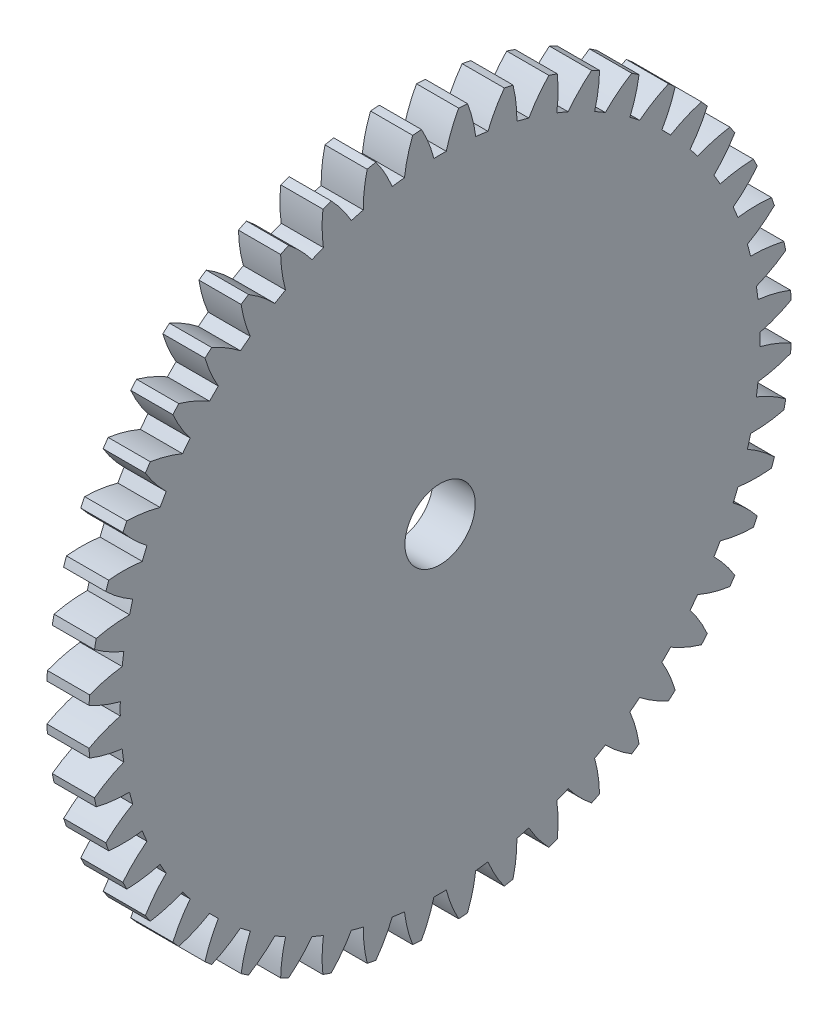
from build123d import *

# Parameters (mm, degrees)
BASPROSKE_W     = 3
BASPROSKE_H     = 25
TOOTHCUT_DEPTH  = 36.482389998
TEETHCUTS_COUNT = 48
TEETHCUTS_ANGLE = 352.5
BORSKE_R        = 2.5
BORE_DEPTH      = 50.0000508


with BuildPart() as part:
    # BasProSke → Base-Revolve (revolve)
    with BuildSketch(Plane(origin=(0, 0, 0), x_dir=(1, 0, 0), z_dir=(0, 1, 0)), mode=Mode.PRIVATE) as base_revolve_sk:
        with Locations((1.5, 12.5)):
            Rectangle(BASPROSKE_W, BASPROSKE_H)
    revolve(base_revolve_sk.sketch.rotate(Axis((-10, 0, 0), (1, 0, 0)), 180), axis=Axis((-10, 0, 0), (1, 0, 0)))

    # TooCutSke → ToothCut (cut, through all)
    with BuildSketch(Plane(origin=(0, 0, 0), x_dir=(0, 0, -1), z_dir=(1, 0, 0))):
        with BuildLine():
            ThreePointArc((0.439519311, 22.744753764), (0, 22.749), (-0.439519311, 22.744753764))
            ThreePointArc((-0.439519311, 22.744753764), (-0.815652087, 23.895542925), (-1.33363602, 24.989839138))
            ThreePointArc((-1.33363602, 24.989839138), (0, 25.0254), (1.33363602, 24.989839138))
            ThreePointArc((1.33363602, 24.989839138), (0.815652087, 23.895542925), (0.439519311, 22.744753764))
        make_face()
    toothcut = extrude(amount=TOOTHCUT_DEPTH, mode=Mode.SUBTRACT)

    # TeethCuts: ToothCut ×48 about axis
    teethcuts_axis = Axis((-10, 0, 0), (1, 0, 0))
    for i in range(1, TEETHCUTS_COUNT):
        add(toothcut.rotate(teethcuts_axis, i * TEETHCUTS_ANGLE / (TEETHCUTS_COUNT - 1)), mode=Mode.SUBTRACT)

    # BorSke → Bore (cut, symmetric)
    with BuildSketch(Plane(origin=(0, 0, 0), x_dir=(0, 0, -1), z_dir=(1, 0, 0))):
        with Locations(Location((0, 0, 0), (0, 0, 180))):
            Circle(BORSKE_R)
    extrude(amount=BORE_DEPTH, both=True, mode=Mode.SUBTRACT)


solid = part.part
